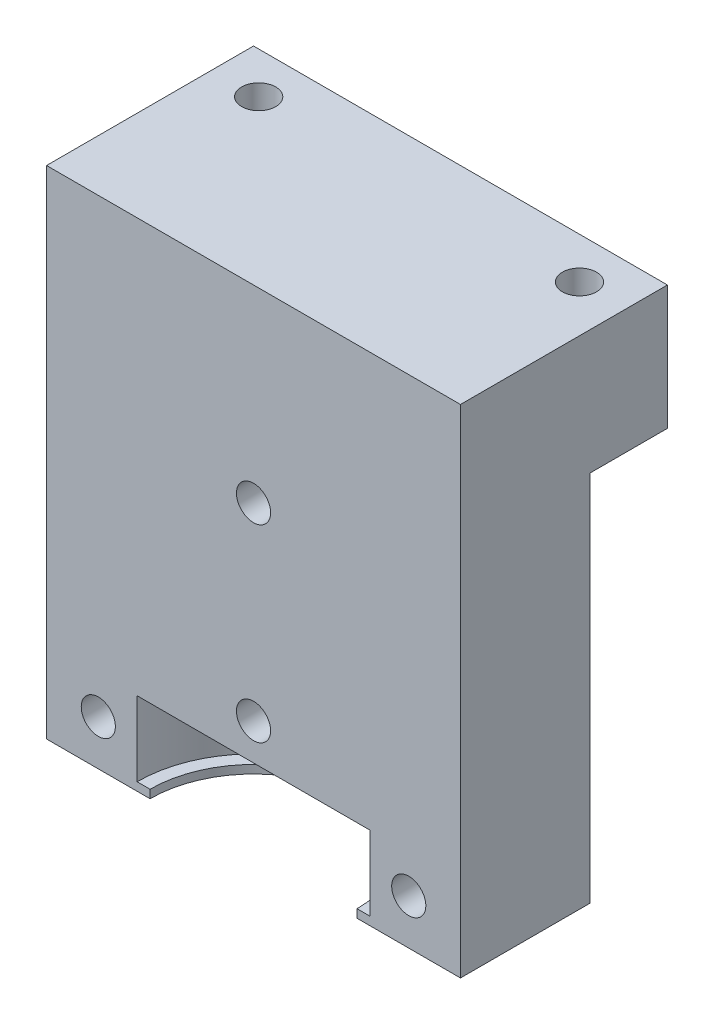
from build123d import *

# Parameters (mm, degrees)
SKETCH1_W             = 40
SKETCH1_H             = 40
BOSS_EXTRUDE1_DEPTH   = 48
M4X0_7_TAPPED_HOLE1_D = 3.3
SKETCH10_W            = 40
SKETCH10_H            = 20
CUT_EXTRUDE4_DEPTH    = 49
SKETCH11_W            = 11.25
SKETCH11_H            = 7.2
CUT_EXTRUDE5_REACH    = 50
SKETCH12_R            = 10
M4X0_7_TAPPED_HOLE2_D = 3.3
SKETCH15_W            = 40
SKETCH15_H            = 7.5
CUT_EXTRUDE6_DEPTH    = 36


with BuildPart() as part:
    # Sketch1 → Boss-Extrude1 (new body)
    with BuildSketch(Plane(origin=(0, 0, 0), x_dir=(1, 0, 0), z_dir=(0, 1, 0))):
        Rectangle(SKETCH1_W, SKETCH1_H)
    extrude(amount=-BOSS_EXTRUDE1_DEPTH)

    # M4x0.7 Tapped Hole1 (through all)
    with Locations(Plane(origin=(0, 0, 0), x_dir=(1, 0, 0), z_dir=(0, 1, 0))):
        with Locations((-15.5, 16), (15.5, 16), (15.5, -16), (-15.5, -16)):
            Hole(M4X0_7_TAPPED_HOLE1_D / 2)

    # Sketch10 → Cut-Extrude4 (cut, through all)
    with BuildSketch(Plane(origin=(0, 0, 0), x_dir=(1, 0, 0), z_dir=(0, 1, 0))):
        with Locations((0, -10)):
            Rectangle(SKETCH10_W, SKETCH10_H)
    extrude(amount=-CUT_EXTRUDE4_DEPTH, mode=Mode.SUBTRACT)

    # Sketch11 → Cut-Revolve2 (revolve, cut)
    with BuildSketch(Plane.XY):
        with Locations((5.625, -43.6)):
            Rectangle(SKETCH11_W, SKETCH11_H)
    revolve(axis=Axis((0, 0, 0), (0, -1, 0)), mode=Mode.SUBTRACT)

    # Sketch12 → Cut-Extrude5 (cut, up to next)
    with BuildSketch(Plane.XZ.offset(48), mode=Mode.PRIVATE) as cut_extrude5_sk1:
        Circle(SKETCH12_R)
    cut_extrude5_tool1 = extrude(cut_extrude5_sk1.sketch, amount=-CUT_EXTRUDE5_REACH, mode=Mode.PRIVATE) & part.part
    add(cut_extrude5_tool1.solids().sort_by_distance((0, -48, 0))[0], mode=Mode.SUBTRACT)

    # M4x0.7 Tapped Hole2 (through all)
    with Locations(Plane(origin=(0, 0, -20), x_dir=(-1, 0, 0), z_dir=(0, 0, -1))):
        with Locations((15, -43.628125), (-15, -43.628125), (0, -36.484375), (0, -18.2421875)):
            Hole(M4X0_7_TAPPED_HOLE2_D / 2)

    # Sketch15 → Cut-Extrude6 (cut)
    with BuildSketch(Plane.XZ.offset(48)):
        with Locations((0, -16.25)):
            Rectangle(SKETCH15_W, SKETCH15_H)
    extrude(amount=-CUT_EXTRUDE6_DEPTH, mode=Mode.SUBTRACT)


solid = part.part
